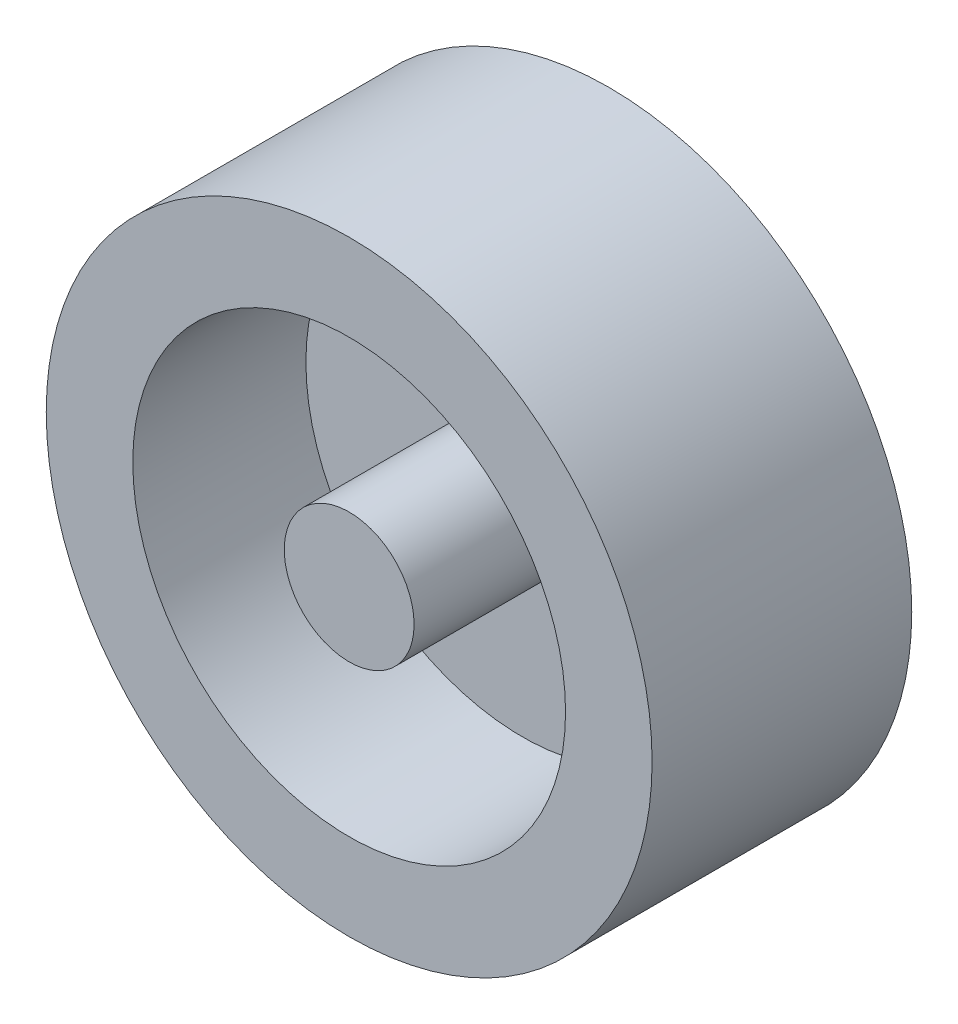
from build123d import *

# Parameters (mm, degrees)
CROQUIS1_R              = 3.5
SALIENTE_EXTRUIR1_DEPTH = 3
CROQUIS2_R              = 2.5
CORTAR_EXTRUIR1_DEPTH   = 2
CROQUIS3_R              = 0.75
SALIENTE_EXTRUIR2_DEPTH = 2


with BuildPart() as part:
    # Croquis1 → Saliente-Extruir1 (new body)
    with BuildSketch(Plane.XY):
        Circle(CROQUIS1_R)
    extrude(amount=SALIENTE_EXTRUIR1_DEPTH)

    # Croquis2 → Cortar-Extruir1 (cut)
    with BuildSketch(Plane.XY.offset(3)):
        Circle(CROQUIS2_R)
    extrude(amount=-CORTAR_EXTRUIR1_DEPTH, mode=Mode.SUBTRACT)

    # Croquis3 → Saliente-Extruir2 (add)
    with BuildSketch(Plane.XY.offset(1)):
        Circle(CROQUIS3_R)
    extrude(amount=SALIENTE_EXTRUIR2_DEPTH)


solid = part.part
